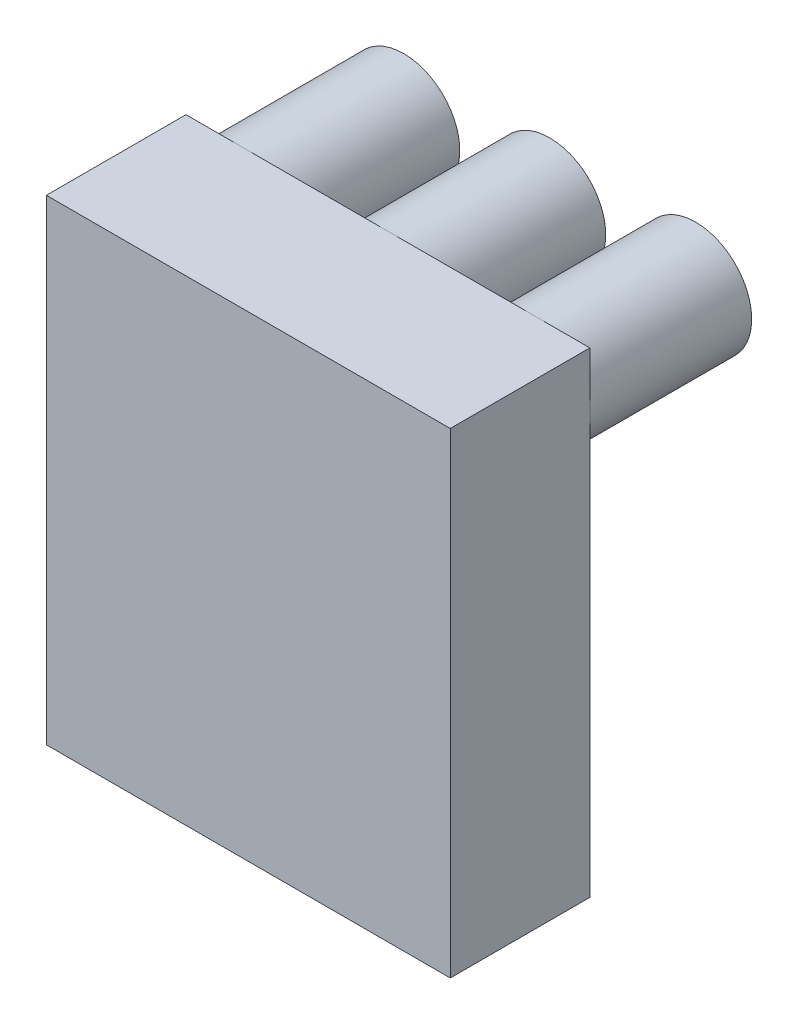
from build123d import *

# Parameters (mm, degrees)
SKETCH1_R                = 11.20775
BOSS_EXTRUDE1_DEPTH      = 60.325
LPATTERN1_COUNT          = 2
LPATTERN1_PITCH          = 29.21
LPATTERN1_2_COUNT        = 2
LPATTERN1_2_PITCH        = 29.21
SKETCH2_W                = 80.8355
SKETCH2_H                = 27.94
BOSS_EXTRUDE2_DEPTH      = 11.20775
BOSS_EXTRUDE2_DEPTH_BACK = 84.04225


with BuildPart() as part:
    # Sketch1 → Boss-Extrude1 (new body)
    with BuildSketch(Plane.XY):
        Circle(SKETCH1_R)
        with BuildLine():
            ThreePointArc((1.7145, -11.075836303), (0, -11.20775), (-1.7145, -11.075836303))
            Line((-1.7145, -11.075836303), (-1.7145, -12.104536303))
            Line((-1.7145, -12.104536303), (1.7145, -12.104536303))
            Line((1.7145, -12.104536303), (1.7145, -11.075836303))
        make_face()
    extrude(amount=BOSS_EXTRUDE1_DEPTH)


with BuildPart() as lpattern1_1:
    # LPattern1: pattern copy
    add(part.part.moved(Location(Vector(1, 0, 0) * (1 * LPATTERN1_PITCH))))


with BuildPart() as lpattern1_2_1:
    # LPattern1 2: pattern copy
    add(part.part.moved(Location(Vector(-1, 0, 0) * (1 * LPATTERN1_2_PITCH))))


with BuildPart() as lpattern1_2_2:
    # LPattern1 2: pattern copy
    add(lpattern1_1.part.moved(Location(Vector(-1, 0, 0) * (1 * LPATTERN1_2_PITCH))))


with BuildPart() as part_1:
    add(part.part)

    add(lpattern1_1.part)  # Boss-Extrude2 merges LPattern1_1

    add(lpattern1_2_1.part)  # Boss-Extrude2 merges LPattern1 2_1

    add(lpattern1_2_2.part)  # Boss-Extrude2 merges LPattern1 2_2
    # Sketch2 → Boss-Extrude2 (add, two sides)
    with BuildSketch(Plane(origin=(0, 0, 0), x_dir=(1, 0, 0), z_dir=(0, 1, 0))) as boss_extrude2_sk:
        with Locations((0, -46.355)):
            Rectangle(SKETCH2_W, SKETCH2_H)
    extrude(amount=BOSS_EXTRUDE2_DEPTH)
    extrude(boss_extrude2_sk.sketch, amount=-BOSS_EXTRUDE2_DEPTH_BACK)


solid = part_1.part
